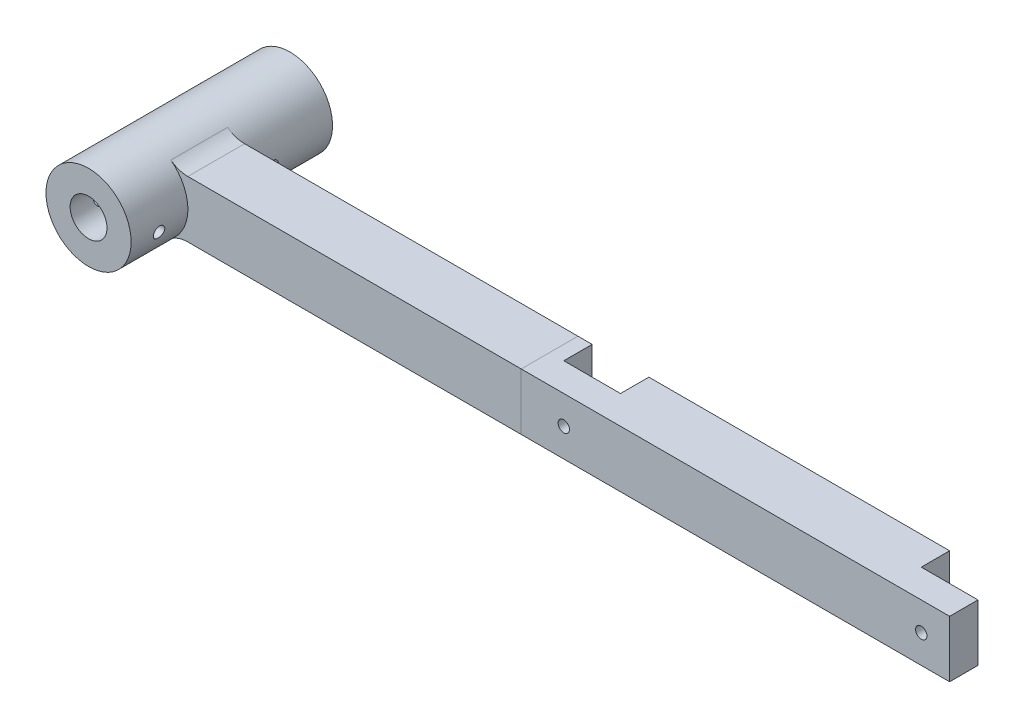
from build123d import *

# Parameters (mm, degrees)
SKETCH1_R              = 6.55
BOSS_EXTRUDE1_DEPTH    = 20
SKETCH2_R              = 15
SKETCH2_R_2            = 6.5
BOSS_EXTRUDE2_DEPTH    = 31
SKETCH3_R              = 15
SKETCH3_R_2            = 6.5
BOSS_EXTRUDE3_DEPTH    = 20
SKETCH4_W              = 146
SKETCH4_H              = 20
BOSS_EXTRUDE4_DEPTH    = 20
SKETCH7_W              = 20
SKETCH7_H              = 10
CUT_EXTRUDE1_DEPTH     = 20
SKETCH8_R              = 2
CUT_EXTRUDE2_DEPTH     = 10
SKETCH9_R              = 2
CUT_EXTRUDE3_DEPTH     = 273.611903629
SPLIT1_SURFACE_1_BACK  = 309.291
SPLIT1_SURFACE_1_DEPTH = 618.582
SPLIT1_SURFACE_2_BACK  = 309.291
SPLIT1_SURFACE_2_DEPTH = 618.582


with BuildPart() as part:
    # Sketch1 → Boss-Extrude1 (new body)
    with BuildSketch(Plane.XY):
        with BuildLine():
            Line((0, 0), (0, 20))
            Line((0, 20), (-122.5, 20))
            ThreePointArc((-122.5, 20), (-125.66227766, 20.513167019), (-128.5, 22))
            ThreePointArc((-128.5, 22), (-152.5, 10), (-128.5, -2))
            ThreePointArc((-128.5, -2), (-125.66227766, -0.513167019), (-122.5, 0))
            Line((-122.5, 0), (0, 0))
        make_face()
        with Locations((-137.5, 10)):
            Circle(SKETCH1_R, mode=Mode.SUBTRACT)
    extrude(amount=BOSS_EXTRUDE1_DEPTH)

    # Sketch2 → Boss-Extrude2 (add)
    with BuildSketch(Plane(origin=(0, 0, 0), x_dir=(-1, 0, 0), z_dir=(0, 0, -1))):
        with Locations((137.5, 10)):
            Circle(SKETCH2_R)
        with Locations((137.5, 10)):
            Circle(SKETCH2_R_2, mode=Mode.SUBTRACT)
    extrude(amount=BOSS_EXTRUDE2_DEPTH)

    # Sketch3 → Boss-Extrude3 (add)
    with BuildSketch(Plane.XY.offset(20)):
        with Locations(Location((-137.5, 10, 0), (0, 0, 180))):
            Circle(SKETCH3_R)
        with Locations(Location((-137.5, 10, 0), (0, 0, 180))):
            Circle(SKETCH3_R_2, mode=Mode.SUBTRACT)
    extrude(amount=BOSS_EXTRUDE3_DEPTH)

    # Sketch4 → Boss-Extrude4 (add)
    with BuildSketch(Plane.XY.offset(20)):
        with Locations((73, 10)):
            Rectangle(SKETCH4_W, SKETCH4_H)
    extrude(amount=-BOSS_EXTRUDE4_DEPTH)

    # Sketch7 → Cut-Extrude1 (cut)
    with BuildSketch(Plane(origin=(0, 20, 0), x_dir=(1, 0, 0), z_dir=(0, 1, 0))):
        with Locations((136, -5)):
            Rectangle(SKETCH7_W, SKETCH7_H)
        with Locations((10, -5)):
            Rectangle(SKETCH7_W, SKETCH7_H)
    extrude(amount=-CUT_EXTRUDE1_DEPTH, mode=Mode.SUBTRACT)

    # Sketch8 → Cut-Extrude2 (cut)
    with BuildSketch(Plane(origin=(0, 0, 10), x_dir=(-1, 0, 0), z_dir=(0, 0, -1))):
        with Locations((-136, 10)):
            Circle(SKETCH8_R)
        with Locations((-10, 10)):
            Circle(SKETCH8_R)
    extrude(amount=-CUT_EXTRUDE2_DEPTH, mode=Mode.SUBTRACT)

    # Sketch9 → Cut-Extrude3 (cut, through all)
    with BuildSketch(Plane(origin=(-122.5, 0, 0), x_dir=(0, 0, -1), z_dir=(1, 0, 0))):
        with Locations((-30, 7.88647696)):
            Circle(SKETCH9_R)
        with Locations((10, 7.88647696)):
            Circle(SKETCH9_R)
    extrude(amount=-CUT_EXTRUDE3_DEPTH, mode=Mode.SUBTRACT)


with BuildPart() as body_2:
    # Split1: the piece behind the surface
    add(part.part)
    # Split1 surface: a surface, the sketch's curves swept straight by 618.582 mm
    with BuildLine(Plane(origin=(0, 20, 0), x_dir=(1, 0, 0), z_dir=(0, 1, 0)).offset(-SPLIT1_SURFACE_1_BACK), mode=Mode.PRIVATE) as split1_surface_1_path:
        Line((-5, 0), (-5, -20))
    split1_surface_1 = Shell.extrude(split1_surface_1_path.wire(), (0 * SPLIT1_SURFACE_1_DEPTH, 1 * SPLIT1_SURFACE_1_DEPTH, 0 * SPLIT1_SURFACE_1_DEPTH))
    split(bisect_by=split1_surface_1, keep=Keep.BOTTOM)


with BuildPart() as part_1:
    add(part.part)

    # Split1: split by a surface, the side it looks to stays
    # Split1 surface: a surface, the sketch's curves swept straight by 618.582 mm
    with BuildLine(Plane(origin=(0, 20, 0), x_dir=(1, 0, 0), z_dir=(0, 1, 0)).offset(-SPLIT1_SURFACE_2_BACK), mode=Mode.PRIVATE) as split1_surface_2_path:
        Line((-5, 0), (-5, -20))
    split1_surface_2 = Shell.extrude(split1_surface_2_path.wire(), (0 * SPLIT1_SURFACE_2_DEPTH, 1 * SPLIT1_SURFACE_2_DEPTH, 0 * SPLIT1_SURFACE_2_DEPTH))
    split(bisect_by=split1_surface_2, keep=Keep.TOP)


solid = Compound([body_2.part, part_1.part])
